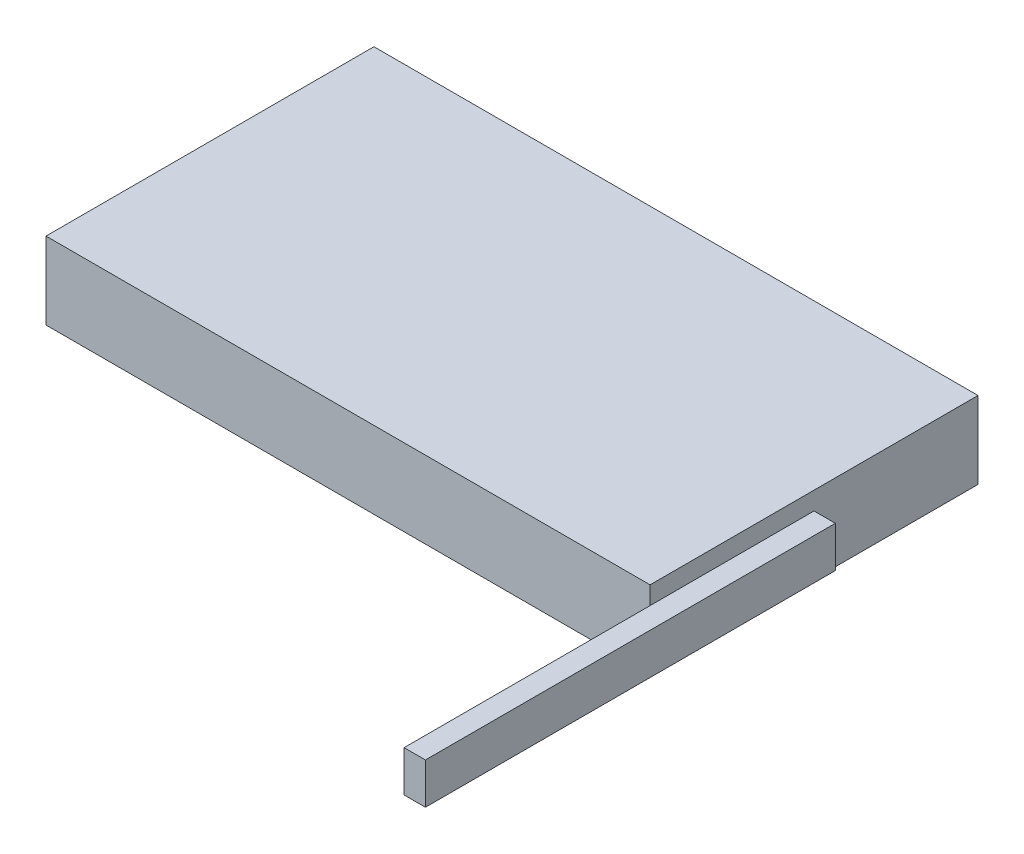
from build123d import *

# Parameters (mm, degrees)
SKETCH1_W                = 36.84
SKETCH1_H                = 20
BOSS_EXTRUDE1_DEPTH      = 4.7
SKETCH2_W                = 1.3
SKETCH2_H                = 2.5
BOSS_EXTRUDE2_DEPTH      = 15
BOSS_EXTRUDE2_DEPTH_BACK = 10


with BuildPart() as part:
    # Sketch1 → Boss-Extrude1 (new body)
    with BuildSketch(Plane(origin=(0, 0, 0), x_dir=(1, 0, 0), z_dir=(0, 1, 0))):
        with Locations((18.42, -10)):
            Rectangle(SKETCH1_W, SKETCH1_H)
    extrude(amount=BOSS_EXTRUDE1_DEPTH)

    # Sketch2 → Boss-Extrude2 (add, two sides)
    with BuildSketch(Plane.XY.offset(20)) as boss_extrude2_sk:
        with Locations((37.49, 2.35)):
            Rectangle(SKETCH2_W, SKETCH2_H)
    extrude(amount=BOSS_EXTRUDE2_DEPTH)
    extrude(boss_extrude2_sk.sketch, amount=-BOSS_EXTRUDE2_DEPTH_BACK)


solid = part.part
